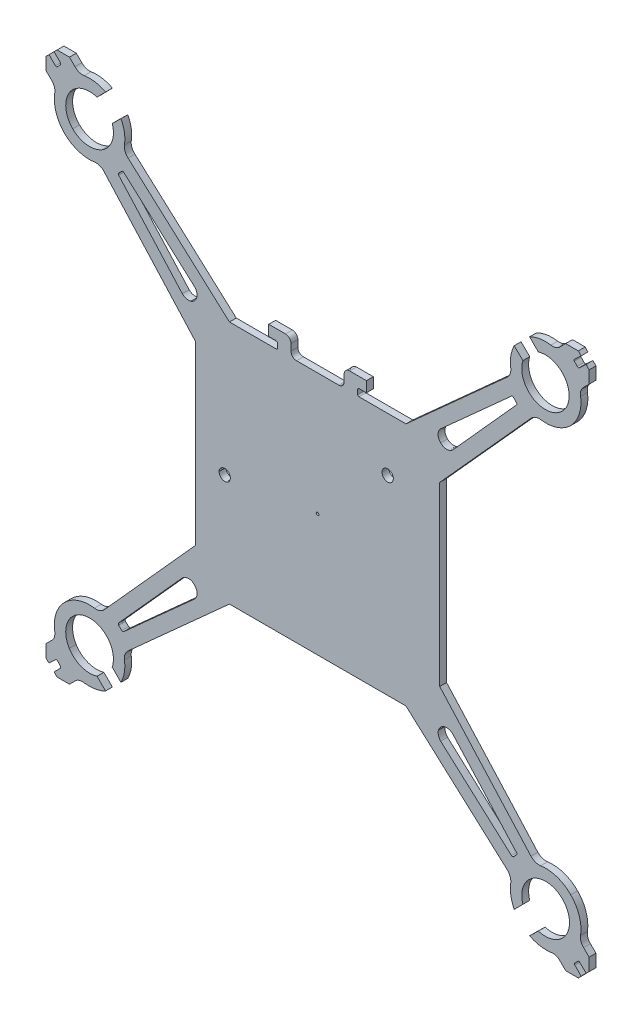
from build123d import *

# Parameters (mm, degrees)
EXTRUDE_1_DEPTH     = 1.26
SKETCH_1_R          = 0.25
CUT_EXTRUDE_1_DEPTH = 2.2600001


with BuildPart() as part:
    # Model → 凸台-拉伸1 (new body)
    with BuildSketch(Plane.XY):
        with BuildLine():
            Line((274.707, 225.998532), (272.592, 225.998532))
            add(Edge.make_bspline(
                [(272.592, 225.998532), (271.9998, 225.998532), (271.5768, 226.421532), (271.5768, 227.013732)],
                knots=[13, 13, 13, 13, 14, 14, 14, 14], degree=3))
            Line((271.5768, 227.013732), (271.5768, 228.240432))
            add(Edge.make_bspline(
                [(271.5768, 228.240432), (271.5768, 228.790332), (271.1115, 229.255632), (270.5616, 229.255632)],
                knots=[16, 16, 16, 16, 17, 17, 17, 17], degree=3))
            Line((270.5616, 229.255632), (267.4737, 229.255632))
            Line((267.4737, 229.255632), (267.4737, 227.309832))
            Line((267.4737, 227.309832), (268.8273, 227.309832))
            add(Edge.make_bspline(
                [(268.8273, 227.309832), (268.9542, 227.309832), (269.0811, 227.182932), (269.0811, 227.056032)],
                knots=[21, 21, 21, 21, 22, 22, 22, 22], degree=3))
            Line((269.0811, 227.056032), (269.0811, 226.252332))
            add(Edge.make_bspline(
                [(269.0811, 226.252332), (269.0811, 226.125432), (268.9542, 225.998532), (268.8273, 225.998532)],
                knots=[24, 24, 24, 24, 25, 25, 25, 25], degree=3))
            Line((268.8273, 225.998532), (260.2404, 225.998532))
            Line((260.2404, 225.998532), (241.5861, 242.791632))
            add(Edge.make_bspline(
                [(241.5861, 242.791632), (241.0785, 243.214632), (240.8247, 243.891432), (240.9093, 244.568232)],
                knots=[28, 28, 28, 28, 29, 29, 29, 29], degree=3))
            add(Edge.make_bspline(
                [(240.9093, 244.568232), (241.1208, 245.879532), (240.9093, 247.233132), (240.2748, 248.417532)],
                knots=[30, 30, 30, 30, 31, 31, 31, 31], degree=3))
            Line((240.2748, 248.417532), (238.6674, 246.852432))
            add(Edge.make_bspline(
                [(238.6674, 246.852432), (239.3019, 244.906632), (238.5405, 242.791632), (236.8062, 241.734132)],
                knots=[33, 33, 33, 33, 34, 34, 34, 34], degree=3))
            add(Edge.make_bspline(
                [(236.8062, 241.734132), (235.0719, 240.676632), (232.83, 240.930432), (231.3918, 242.368632)],
                knots=[34, 34, 34, 34, 35, 35, 35, 35], degree=3))
            add(Edge.make_bspline(
                [(231.3918, 242.368632), (229.9536, 243.806832), (229.6998, 246.048732), (230.7573, 247.783032)],
                knots=[35, 35, 35, 35, 36, 36, 36, 36], degree=3))
            add(Edge.make_bspline(
                [(230.7573, 247.783032), (231.8148, 249.517332), (233.9298, 250.278732), (235.8756, 249.644232)],
                knots=[36, 36, 36, 36, 37, 37, 37, 37], degree=3))
            Line((235.8756, 249.644232), (237.4407, 251.251632))
            add(Edge.make_bspline(
                [(237.4407, 251.251632), (236.2563, 251.886132), (234.8604, 252.097632), (233.5068, 251.886132)],
                knots=[39, 39, 39, 39, 40, 40, 40, 40], degree=3))
            add(Edge.make_bspline(
                [(233.5068, 251.886132), (232.8723, 251.801532), (232.2378, 252.013032), (231.8148, 252.478332)],
                knots=[41, 41, 41, 41, 42, 42, 42, 42], degree=3))
            Line((231.8148, 252.478332), (230.7996, 253.493532))
            Line((230.7996, 253.493532), (228.5154, 253.493532))
            Line((228.5154, 253.493532), (227.9655, 252.943632))
            Line((227.9655, 252.943632), (229.1499, 251.759232))
            ThreePointArc((229.1499, 251.759232), (229.183048726, 251.583244659), (229.1076, 251.420832))
            Line((229.1076, 251.420832), (228.6, 250.870932))
            ThreePointArc((228.6, 250.870932), (228.419815216, 250.75829506), (228.2193, 250.828632))
            Line((228.2193, 250.828632), (227.0349, 252.013032))
            Line((227.0349, 252.013032), (226.485, 251.463132))
            Line((226.485, 251.463132), (226.485, 249.178932))
            Line((226.485, 249.178932), (227.5002, 248.163732))
            add(Edge.make_bspline(
                [(227.5002, 248.163732), (227.9655, 247.740732), (228.177, 247.106232), (228.0924, 246.471732)],
                knots=[59, 59, 59, 59, 60, 60, 60, 60], degree=3))
            add(Edge.make_bspline(
                [(228.0924, 246.471732), (227.754, 244.441332), (228.4308, 242.368632), (229.869, 240.888132)],
                knots=[61, 61, 61, 61, 62, 62, 62, 62], degree=3))
            add(Edge.make_bspline(
                [(229.869, 240.888132), (231.3495, 239.449932), (233.3799, 238.773132), (235.4103, 239.069232)],
                knots=[62, 62, 62, 62, 63, 63, 63, 63], degree=3))
            add(Edge.make_bspline(
                [(235.4103, 239.069232), (236.0871, 239.153832), (236.7639, 238.900032), (237.1869, 238.392432)],
                knots=[64, 64, 64, 64, 65, 65, 65, 65], degree=3))
            Line((237.1869, 238.392432), (253.98, 219.780432))
            Line((253.98, 219.780432), (253.98, 187.251732))
            Line((253.98, 187.251732), (237.1869, 168.597432))
            add(Edge.make_bspline(
                [(237.1869, 168.597432), (236.7639, 168.132132), (236.0871, 167.878332), (235.4103, 167.962932)],
                knots=[221, 221, 221, 221, 222, 222, 222, 222], degree=3))
            add(Edge.make_bspline(
                [(235.4103, 167.962932), (233.3799, 168.259032), (231.3495, 167.582232), (229.869, 166.101732)],
                knots=[223, 223, 223, 223, 224, 224, 224, 224], degree=3))
            add(Edge.make_bspline(
                [(229.869, 166.101732), (228.4308, 164.663532), (227.754, 162.590832), (228.0924, 160.560432)],
                knots=[224, 224, 224, 224, 225, 225, 225, 225], degree=3))
            add(Edge.make_bspline(
                [(228.0924, 160.560432), (228.177, 159.925932), (227.9655, 159.291432), (227.5002, 158.868432)],
                knots=[226, 226, 226, 226, 227, 227, 227, 227], degree=3))
            Line((227.5002, 158.868432), (226.485, 157.853232))
            Line((226.485, 157.853232), (226.485, 155.526732))
            Line((226.485, 155.526732), (227.0349, 155.019132))
            Line((227.0349, 155.019132), (228.2193, 156.161232))
            ThreePointArc((228.2193, 156.161232), (228.40965, 156.23805797), (228.6, 156.161232))
            Line((228.6, 156.161232), (229.1076, 155.611332))
            ThreePointArc((229.1076, 155.611332), (229.183048726, 155.448919341), (229.1499, 155.272932))
            Line((229.1499, 155.272932), (227.9655, 154.088532))
            Line((227.9655, 154.088532), (228.5154, 153.538632))
            Line((228.5154, 153.538632), (230.7996, 153.538632))
            Line((230.7996, 153.538632), (231.8148, 154.553832))
            add(Edge.make_bspline(
                [(231.8148, 154.553832), (232.2378, 155.019132), (232.8723, 155.230632), (233.5068, 155.103732)],
                knots=[244, 244, 244, 244, 245, 245, 245, 245], degree=3))
            add(Edge.make_bspline(
                [(233.5068, 155.103732), (234.8604, 154.934532), (236.2563, 155.146032), (237.4407, 155.780532)],
                knots=[246, 246, 246, 246, 247, 247, 247, 247], degree=3))
            Line((237.4407, 155.780532), (235.8756, 157.345632))
            add(Edge.make_bspline(
                [(235.8756, 157.345632), (233.9298, 156.753432), (231.8148, 157.514832), (230.7573, 159.249132)],
                knots=[249, 249, 249, 249, 250, 250, 250, 250], degree=3))
            add(Edge.make_bspline(
                [(230.7573, 159.249132), (229.6998, 160.983432), (229.9536, 163.225332), (231.3918, 164.663532)],
                knots=[250, 250, 250, 250, 251, 251, 251, 251], degree=3))
            add(Edge.make_bspline(
                [(231.3918, 164.663532), (232.83, 166.101732), (235.0719, 166.355532), (236.8062, 165.298032)],
                knots=[251, 251, 251, 251, 252, 252, 252, 252], degree=3))
            add(Edge.make_bspline(
                [(236.8062, 165.298032), (238.5405, 164.240532), (239.3019, 162.125532), (238.6674, 160.179732)],
                knots=[252, 252, 252, 252, 253, 253, 253, 253], degree=3))
            Line((238.6674, 160.179732), (240.2748, 158.572332))
            add(Edge.make_bspline(
                [(240.2748, 158.572332), (240.9093, 159.799032), (241.1208, 161.152632), (240.9093, 162.463932)],
                knots=[255, 255, 255, 255, 256, 256, 256, 256], degree=3))
            add(Edge.make_bspline(
                [(240.9093, 162.463932), (240.8247, 163.140732), (241.0785, 163.775232), (241.5861, 164.240532)],
                knots=[257, 257, 257, 257, 258, 258, 258, 258], degree=3))
            Line((241.5861, 164.240532), (260.2404, 181.033632))
            Line((260.2404, 181.033632), (292.7268, 181.033632))
            Line((292.7268, 181.033632), (311.3811, 164.240532))
            add(Edge.make_bspline(
                [(311.3811, 164.240532), (311.8464, 163.775232), (312.1002, 163.140732), (312.0156, 162.463932)],
                knots=[278, 278, 278, 278, 279, 279, 279, 279], degree=3))
            add(Edge.make_bspline(
                [(312.0156, 162.463932), (311.8041, 161.152632), (312.0579, 159.799032), (312.6501, 158.572332)],
                knots=[280, 280, 280, 280, 281, 281, 281, 281], degree=3))
            Line((312.6501, 158.572332), (314.2575, 160.179732))
            add(Edge.make_bspline(
                [(314.2575, 160.179732), (313.623, 162.125532), (314.4267, 164.240532), (316.161, 165.298032)],
                knots=[283, 283, 283, 283, 284, 284, 284, 284], degree=3))
            add(Edge.make_bspline(
                [(316.161, 165.298032), (317.8953, 166.355532), (320.0949, 166.101732), (321.5331, 164.663532)],
                knots=[284, 284, 284, 284, 285, 285, 285, 285], degree=3))
            add(Edge.make_bspline(
                [(321.5331, 164.663532), (322.9713, 163.225332), (323.2674, 160.983432), (322.1676, 159.249132)],
                knots=[285, 285, 285, 285, 286, 286, 286, 286], degree=3))
            add(Edge.make_bspline(
                [(322.1676, 159.249132), (321.1101, 157.514832), (318.9951, 156.753432), (317.0916, 157.345632)],
                knots=[286, 286, 286, 286, 287, 287, 287, 287], degree=3))
            Line((317.0916, 157.345632), (315.4842, 155.780532))
            add(Edge.make_bspline(
                [(315.4842, 155.780532), (316.7109, 155.146032), (318.0645, 154.934532), (319.4181, 155.103732)],
                knots=[289, 289, 289, 289, 290, 290, 290, 290], degree=3))
            add(Edge.make_bspline(
                [(319.4181, 155.103732), (320.0526, 155.230632), (320.6871, 155.019132), (321.1101, 154.553832)],
                knots=[291, 291, 291, 291, 292, 292, 292, 292], degree=3))
            Line((321.1101, 154.553832), (322.1253, 153.538632))
            Line((322.1253, 153.538632), (324.4518, 153.538632))
            Line((324.4518, 153.538632), (324.9594, 154.088532))
            Line((324.9594, 154.088532), (323.8173, 155.272932))
            ThreePointArc((323.8173, 155.272932), (323.747215065, 155.442132), (323.8173, 155.611332))
            Line((323.8173, 155.611332), (324.3672, 156.161232))
            ThreePointArc((324.3672, 156.161232), (324.5364, 156.231316935), (324.7056, 156.161232))
            Line((324.7056, 156.161232), (325.89, 155.019132))
            Line((325.89, 155.019132), (326.4399, 155.526732))
            Line((326.4399, 155.526732), (326.4399, 157.853232))
            Line((326.4399, 157.853232), (325.4247, 158.868432))
            add(Edge.make_bspline(
                [(325.4247, 158.868432), (324.9594, 159.291432), (324.7479, 159.925932), (324.8748, 160.560432)],
                knots=[309, 309, 309, 309, 310, 310, 310, 310], degree=3))
            add(Edge.make_bspline(
                [(324.8748, 160.560432), (325.1709, 162.590832), (324.4941, 164.663532), (323.0559, 166.101732)],
                knots=[311, 311, 311, 311, 312, 312, 312, 312], degree=3))
            add(Edge.make_bspline(
                [(323.0559, 166.101732), (321.6177, 167.582232), (319.545, 168.259032), (317.5146, 167.962932)],
                knots=[312, 312, 312, 312, 313, 313, 313, 313], degree=3))
            add(Edge.make_bspline(
                [(317.5146, 167.962932), (316.8378, 167.878332), (316.2033, 168.132132), (315.738, 168.597432)],
                knots=[314, 314, 314, 314, 315, 315, 315, 315], degree=3))
            Line((315.738, 168.597432), (298.9449, 187.251732))
            Line((298.9449, 187.251732), (298.9449, 219.780432))
            Line((298.9449, 219.780432), (315.738, 238.392432))
            add(Edge.make_bspline(
                [(315.738, 238.392432), (316.2033, 238.900032), (316.8378, 239.153832), (317.5146, 239.069232)],
                knots=[471, 471, 471, 471, 472, 472, 472, 472], degree=3))
            add(Edge.make_bspline(
                [(317.5146, 239.069232), (319.545, 238.773132), (321.6177, 239.449932), (323.0559, 240.888132)],
                knots=[473, 473, 473, 473, 474, 474, 474, 474], degree=3))
            add(Edge.make_bspline(
                [(323.0559, 240.888132), (324.4941, 242.368632), (325.1709, 244.441332), (324.8748, 246.471732)],
                knots=[474, 474, 474, 474, 475, 475, 475, 475], degree=3))
            add(Edge.make_bspline(
                [(324.8748, 246.471732), (324.7479, 247.106232), (324.9594, 247.740732), (325.4247, 248.163732)],
                knots=[476, 476, 476, 476, 477, 477, 477, 477], degree=3))
            Line((325.4247, 248.163732), (326.4399, 249.178932))
            Line((326.4399, 249.178932), (326.4399, 251.463132))
            Line((326.4399, 251.463132), (325.890287513, 252.058545528))
            Line((325.890287513, 252.058545528), (324.594638272, 250.862561613))
            ThreePointArc((324.594638272, 250.862561613), (324.416847565, 250.832739898), (324.258199315, 250.918352998))
            Line((324.258199315, 250.918352998), (323.730717133, 251.489792029))
            ThreePointArc((323.730717133, 251.489792029), (323.672377713, 251.662675349), (323.750386877, 251.827619886))
            Line((323.750386877, 251.827619886), (324.9594, 252.943632))
            Line((324.9594, 252.943632), (324.4518, 253.493532))
            Line((324.4518, 253.493532), (322.1253, 253.493532))
            Line((322.1253, 253.493532), (321.1101, 252.478332))
            add(Edge.make_bspline(
                [(321.1101, 252.478332), (320.6871, 252.013032), (320.0526, 251.801532), (319.4181, 251.886132)],
                knots=[494, 494, 494, 494, 495, 495, 495, 495], degree=3))
            add(Edge.make_bspline(
                [(319.4181, 251.886132), (318.0645, 252.097632), (316.7109, 251.886132), (315.4842, 251.251632)],
                knots=[496, 496, 496, 496, 497, 497, 497, 497], degree=3))
            Line((315.4842, 251.251632), (317.0916, 249.644232))
            ThreePointArc((317.0916, 249.644232), (321.463183834, 242.369949736), (314.257007336, 246.852911699))
            Line((314.257007336, 246.852911699), (312.6501, 248.417532))
            add(Edge.make_bspline(
                [(312.6501, 248.417532), (312.0579, 247.233132), (311.8041, 245.879532), (312.0156, 244.568232)],
                knots=[505, 505, 505, 505, 506, 506, 506, 506], degree=3))
            add(Edge.make_bspline(
                [(312.0156, 244.568232), (312.1002, 243.891432), (311.8464, 243.214632), (311.3811, 242.791632)],
                knots=[507, 507, 507, 507, 508, 508, 508, 508], degree=3))
            Line((311.3811, 242.791632), (292.7268, 225.998532))
            Line((292.7268, 225.998532), (284.0976, 225.998532))
            add(Edge.make_bspline(
                [(284.0976, 225.998532), (283.9707, 225.998532), (283.8438, 226.125432), (283.8438, 226.252332)],
                knots=[511, 511, 511, 511, 512, 512, 512, 512], degree=3))
            Line((283.8438, 226.252332), (283.8438, 227.056032))
            add(Edge.make_bspline(
                [(283.8438, 227.056032), (283.8438, 227.182932), (283.9707, 227.309832), (284.0976, 227.309832)],
                knots=[514, 514, 514, 514, 515, 515, 515, 515], degree=3))
            Line((284.0976, 227.309832), (285.4512, 227.309832))
            Line((285.4512, 227.309832), (285.4512, 229.255632))
            Line((285.4512, 229.255632), (282.3633, 229.255632))
            add(Edge.make_bspline(
                [(282.3633, 229.255632), (281.8134, 229.255632), (281.3481, 228.790332), (281.3481, 228.240432)],
                knots=[519, 519, 519, 519, 520, 520, 520, 520], degree=3))
            Line((281.3481, 228.240432), (281.3481, 227.013732))
            add(Edge.make_bspline(
                [(281.3481, 227.013732), (281.3481, 226.421532), (280.9251, 225.998532), (280.3752, 225.998532)],
                knots=[522, 522, 522, 522, 523, 523, 523, 523], degree=3))
            Line((280.3752, 225.998532), (278.2179, 225.998532))
            Line((278.2179, 225.998532), (274.707, 225.998532))
        make_face()
        with BuildLine():
            Line((239.8518, 239.534532), (240.444, 240.126732))
            ThreePointArc((240.444, 240.126732), (240.6132, 240.196816935), (240.7824, 240.126732))
            Line((240.7824, 240.126732), (253.8108, 228.409632))
            add(Edge.make_bspline(
                [(253.8108, 228.409632), (254.2338, 227.986632), (254.3607, 227.394432), (254.2338, 226.886832)],
                knots=[1, 1, 1, 1, 2, 2, 2, 2], degree=3))
            add(Edge.make_bspline(
                [(254.2338, 226.886832), (254.0646, 226.336932), (253.6416, 225.913932), (253.134, 225.744732)],
                knots=[2, 2, 2, 2, 3, 3, 3, 3], degree=3))
            add(Edge.make_bspline(
                [(253.134, 225.744732), (252.5841, 225.617832), (251.9919, 225.744732), (251.5689, 226.167732)],
                knots=[3, 3, 3, 3, 4, 4, 4, 4], degree=3))
            Line((251.5689, 226.167732), (239.8518, 239.196132))
            ThreePointArc((239.8518, 239.196132), (239.781715065, 239.365332), (239.8518, 239.534532))
        make_face(mode=Mode.SUBTRACT)
        with BuildLine():
            Line((312.5232, 240.126732), (313.0731, 239.534532))
            ThreePointArc((313.0731, 239.534532), (313.139543189, 239.365332), (313.0731, 239.196132))
            Line((313.0731, 239.196132), (301.356, 226.167732))
            add(Edge.make_bspline(
                [(301.356, 226.167732), (300.7215, 225.533232), (299.7486, 225.533232), (299.1141, 226.167732)],
                knots=[9, 9, 9, 9, 10, 10, 10, 10], degree=3))
            add(Edge.make_bspline(
                [(299.1141, 226.167732), (298.4796, 226.759932), (298.4796, 227.775132), (299.1141, 228.409632)],
                knots=[10, 10, 10, 10, 11, 11, 11, 11], degree=3))
            Line((299.1141, 228.409632), (312.1425, 240.126732))
            ThreePointArc((312.1425, 240.126732), (312.33285, 240.199736966), (312.5232, 240.126732))
        make_face(mode=Mode.SUBTRACT)
        with BuildLine():
            Line((312.5232, 166.905432), (313.0731, 167.455332))
            ThreePointArc((313.0731, 167.455332), (313.146104966, 167.645682), (313.0731, 167.836032))
            Line((313.0731, 167.836032), (301.356, 180.864432))
            add(Edge.make_bspline(
                [(299.8332, 181.287432), (300.3831, 181.414332), (300.933, 181.245132), (301.356, 180.864432)],
                knots=[3, 3, 3, 3, 4, 4, 4, 4], degree=3))
            add(Edge.make_bspline(
                [(298.6911, 180.145332), (298.8603, 180.695232), (299.2833, 181.118232), (299.8332, 181.287432)],
                knots=[2, 2, 2, 2, 3, 3, 3, 3], degree=3))
            add(Edge.make_bspline(
                [(299.1141, 178.622532), (298.7334, 179.045532), (298.5642, 179.595432), (298.6911, 180.145332)],
                knots=[1, 1, 1, 1, 2, 2, 2, 2], degree=3))
            Line((299.1141, 178.622532), (312.1425, 166.905432))
            ThreePointArc((312.1425, 166.905432), (312.33285, 166.832427034), (312.5232, 166.905432))
        make_face(mode=Mode.SUBTRACT)
        with BuildLine():
            Line((239.8518, 167.455332), (240.444, 166.905432))
            ThreePointArc((240.444, 166.905432), (240.6132, 166.838988811), (240.7824, 166.905432))
            Line((240.7824, 166.905432), (253.8108, 178.622532))
            add(Edge.make_bspline(
                [(254.2338, 180.145332), (254.3607, 179.595432), (254.2338, 179.045532), (253.8108, 178.622532)],
                knots=[11, 11, 11, 11, 12, 12, 12, 12], degree=3))
            add(Edge.make_bspline(
                [(253.134, 181.287432), (253.6416, 181.118232), (254.0646, 180.695232), (254.2338, 180.145332)],
                knots=[10, 10, 10, 10, 11, 11, 11, 11], degree=3))
            add(Edge.make_bspline(
                [(251.5689, 180.864432), (251.9919, 181.245132), (252.5841, 181.414332), (253.134, 181.287432)],
                knots=[9, 9, 9, 9, 10, 10, 10, 10], degree=3))
            Line((251.5689, 180.864432), (239.8518, 167.836032))
            ThreePointArc((239.8518, 167.836032), (239.778795034, 167.645682), (239.8518, 167.455332))
        make_face(mode=Mode.SUBTRACT)
        with BuildLine():
            add(Edge.make_bspline(
                [(258.3369, 201.210732), (258.3369, 201.760632), (258.8022, 202.225932), (259.3944, 202.225932), (259.9443, 202.225932), (260.4096, 201.760632), (260.4096, 201.210732)],
                knots=[2, 2, 2, 2, 3, 3, 3, 4, 4, 4, 4], degree=3))
            add(Edge.make_bspline(
                [(260.4096, 201.210732), (260.4096, 200.618532), (259.9443, 200.153232), (259.3944, 200.153232), (258.8022, 200.153232), (258.3369, 200.618532), (258.3369, 201.210732)],
                knots=[0, 0, 0, 0, 1, 1, 1, 2, 2, 2, 2], degree=3))
        make_face(mode=Mode.SUBTRACT)
        with BuildLine():
            add(Edge.make_bspline(
                [(288.3276, 216.100332), (288.3276, 216.692532), (288.7929, 217.157832), (289.3428, 217.157832), (289.935, 217.157832), (290.4003, 216.692532), (290.4003, 216.100332)],
                knots=[2, 2, 2, 2, 3, 3, 3, 4, 4, 4, 4], degree=3))
            add(Edge.make_bspline(
                [(290.4003, 216.100332), (290.4003, 215.508132), (289.935, 215.042832), (289.3428, 215.042832), (288.7929, 215.042832), (288.3276, 215.508132), (288.3276, 216.100332)],
                knots=[0, 0, 0, 0, 1, 1, 1, 2, 2, 2, 2], degree=3))
        make_face(mode=Mode.SUBTRACT)
    extrude(amount=EXTRUDE_1_DEPTH)

    # 草图1 → 切除-拉伸1 (cut, through all)
    with BuildSketch(Plane.XY.offset(1.26)):
        with Locations((276.46245, 203.516082)):
            Circle(SKETCH_1_R)
    extrude(amount=-CUT_EXTRUDE_1_DEPTH, mode=Mode.SUBTRACT)


solid = part.part
